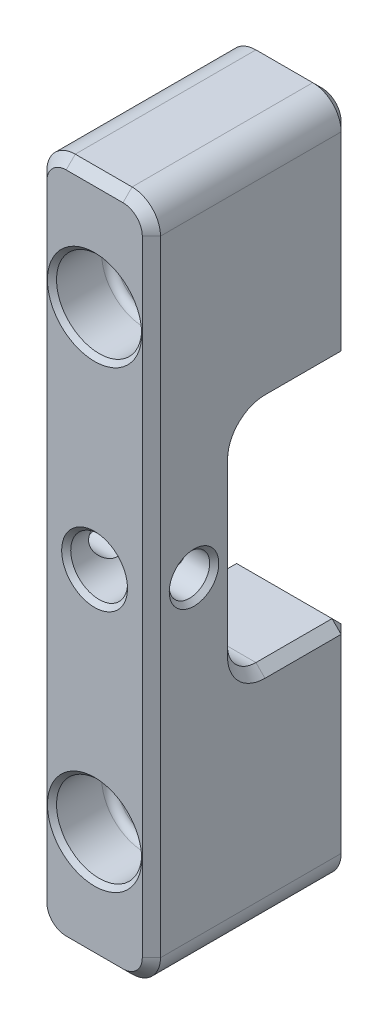
from build123d import *

# Parameters (mm, degrees)
SKETCH1_W                                           = 6.35
SKETCH1_H                                           = 38.1
BOSS_EXTRUDE1_DEPTH                                 = 5.55625
SKETCH8_W                                           = 6.35
SKETCH8_H                                           = 12.7
CUT_EXTRUDE1_DEPTH                                  = 4.175
CUT_EXTRUDE1_DEPTH_BACK                             = 4.175
F_1_8_0_125_DIAMETER_HOLE1_D                        = 3.175
CBORE_FOR_2_BINDING_HEAD_MACHINE_SCREW2_D           = 2.4384
CBORE_FOR_2_BINDING_HEAD_MACHINE_SCREW2_CBORE_D     = 4.7625
CBORE_FOR_2_BINDING_HEAD_MACHINE_SCREW2_CBORE_DEPTH = 3.175
F_4_40_TAPPED_HOLE1_D                               = 2.2606
FILLET1_R                                           = 1.5875
FILLET2_R                                           = 0.396875
CHAMFER1_SIZE                                       = 0.508
CHAMFER2_SIZE                                       = 0.254


with BuildPart() as part:
    # Sketch1 → Boss-Extrude1 (new body, symmetric)
    with BuildSketch(Plane.XY):
        Rectangle(SKETCH1_W, SKETCH1_H)
    extrude(amount=BOSS_EXTRUDE1_DEPTH, both=True)

    # Sketch8 → Cut-Extrude1 (cut, two sides)
    with BuildSketch(Plane(origin=(0, 0, 0), x_dir=(0, 0, -1), z_dir=(1, 0, 0))) as cut_extrude1_sk:
        with Locations((2.38125, 0)):
            Rectangle(SKETCH8_W, SKETCH8_H)
    extrude(amount=CUT_EXTRUDE1_DEPTH, mode=Mode.SUBTRACT)
    extrude(cut_extrude1_sk.sketch, amount=-CUT_EXTRUDE1_DEPTH_BACK, mode=Mode.SUBTRACT)

    # 1/8 (0.125) Diameter Hole1 (through all)
    with Locations(Plane.XY.offset(5.55625)):
        with Locations((0, 0)):
            Hole(F_1_8_0_125_DIAMETER_HOLE1_D / 2)

    # CBORE for #2 Binding Head Machine Screw2 (through all)
    with Locations(Plane.XY.offset(5.55625)):
        with Locations((0, 12.7), (0, -12.7)):
            CounterBoreHole(CBORE_FOR_2_BINDING_HEAD_MACHINE_SCREW2_D / 2, CBORE_FOR_2_BINDING_HEAD_MACHINE_SCREW2_CBORE_D / 2, CBORE_FOR_2_BINDING_HEAD_MACHINE_SCREW2_CBORE_DEPTH)

    # #4-40 Tapped Hole1 (through all)
    with Locations(Plane(origin=(3.175, 0, 0), x_dir=(0, 0, -1), z_dir=(1, 0, 0))):
        with Locations((-3.175, 0)):
            Hole(F_4_40_TAPPED_HOLE1_D / 2)

    # Fillet1
    fillet1_edges = [part.edges().sort_by_distance(p)[0] for p in [
        (0, -6.35, 0.79375),
        (0, 6.35, 0.79375),
        (-3.175, -19.05, 0),
        (3.175, -19.05, 0),
        (3.175, 19.05, 0),
        (-3.175, 19.05, 0),
    ]]
    fillet(fillet1_edges, radius=FILLET1_R)

    # Fillet2
    fillet2_edges = [part.edges().sort_by_distance(p)[0] for p in [
        (-2.38125, -12.7, 2.38125),
        (-2.38125, 12.7, 2.38125),
    ]]
    fillet(fillet2_edges, radius=FILLET2_R)

    # Chamfer1
    chamfer1_edges = [part.edges().sort_by_distance(p)[0] for p in [
        (-3.175, 11.90625, -5.55625),
        (3.175, 11.90625, -5.55625),
        (0, 6.35, -5.55625),
        (0, -6.35, -5.55625),
        (-3.175, -6.35, -3.175),
        (3.175, -6.35, -3.175),
        (-3.175, 0, 0.79375),
        (3.175, 0, 0.79375),
        (-3.175, 6.35, -3.175),
        (3.175, 6.35, -3.175),
        (0, -19.05, -5.55625),
        (0, -19.05, 5.55625),
        (3.175, -11.90625, -5.55625),
        (-3.175, -11.90625, -5.55625),
        (2.710032015, -18.585032015, -5.55625),
        (-2.710032015, -18.585032015, -5.55625),
        (-3.175, 0, 5.55625),
        (3.175, 0, 5.55625),
        (0, 19.05, 5.55625),
        (2.710032015, 18.585032015, 5.55625),
        (-2.710032015, 18.585032015, 5.55625),
        (2.710032015, -18.585032015, 5.55625),
        (-2.710032015, -18.585032015, 5.55625),
        (0, 19.05, -5.55625),
        (2.710032015, 18.585032015, -5.55625),
        (-2.710032015, 18.585032015, -5.55625),
        (3.175, -5.885032015, 0.328782015),
        (-3.175, -5.885032015, 0.328782015),
        (3.175, 5.885032015, 0.328782015),
        (-3.175, 5.885032015, 0.328782015),
    ]]
    chamfer(chamfer1_edges, length=CHAMFER1_SIZE)

    # Chamfer2
    chamfer2_edges = [part.edges().sort_by_distance(p)[0] for p in [
        (1.5875, 0, 0.79375),
        (1.5875, 0, 5.55625),
        (-2.38125, -12.7, 5.55625),
        (1.2192, -12.7, -5.55625),
        (1.2192, -12.7, 2.38125),
        (-2.38125, 12.7, 5.55625),
        (1.2192, 12.7, -5.55625),
        (1.2192, 12.7, 2.38125),
        (-3.175, 0, 2.0447),
        (3.175, 0, 2.0447),
    ]]
    chamfer(chamfer2_edges, length=CHAMFER2_SIZE)


solid = part.part
